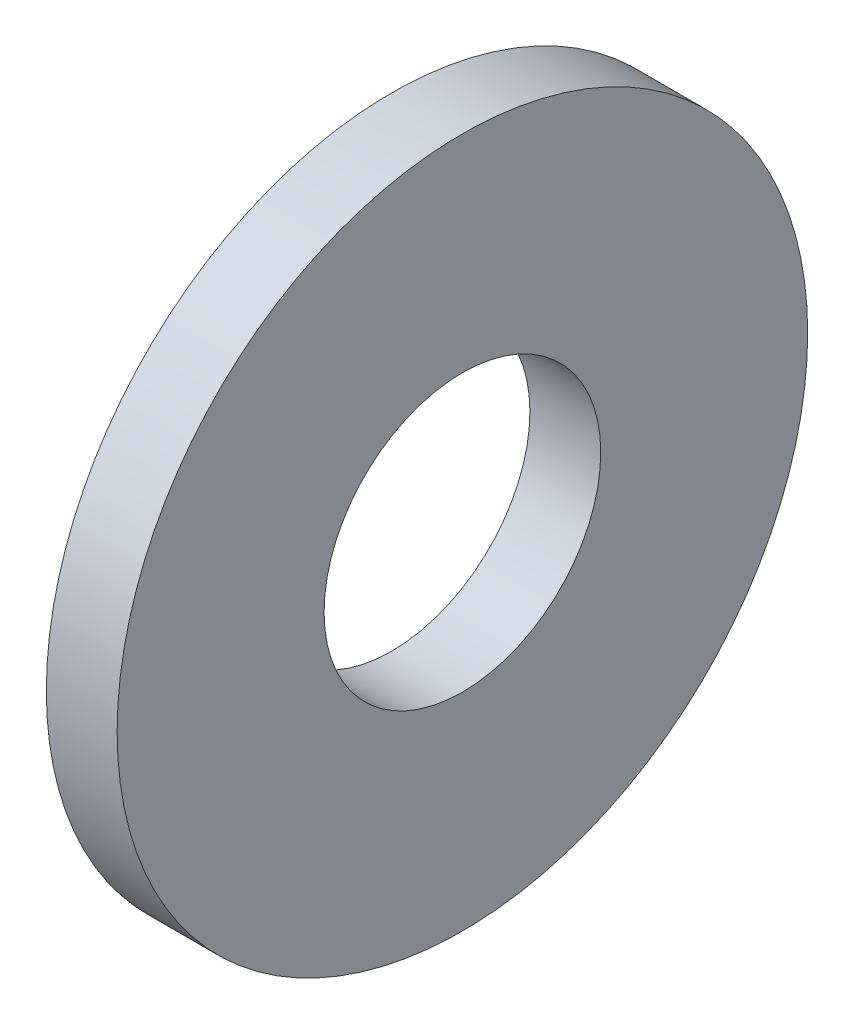
from build123d import *

# Parameters (mm, degrees)
SKETCH1_W = 0.8128
SKETCH1_H = 2.3749


with BuildPart() as part:
    # Sketch1 → Base-Revolve (revolve)
    with BuildSketch(Plane.XY):
        with Locations((-0.4064, 2.77495)):
            Rectangle(SKETCH1_W, SKETCH1_H)
    revolve(axis=Axis((-34.925, 0, 0), (1, 0, 0)))


solid = part.part
